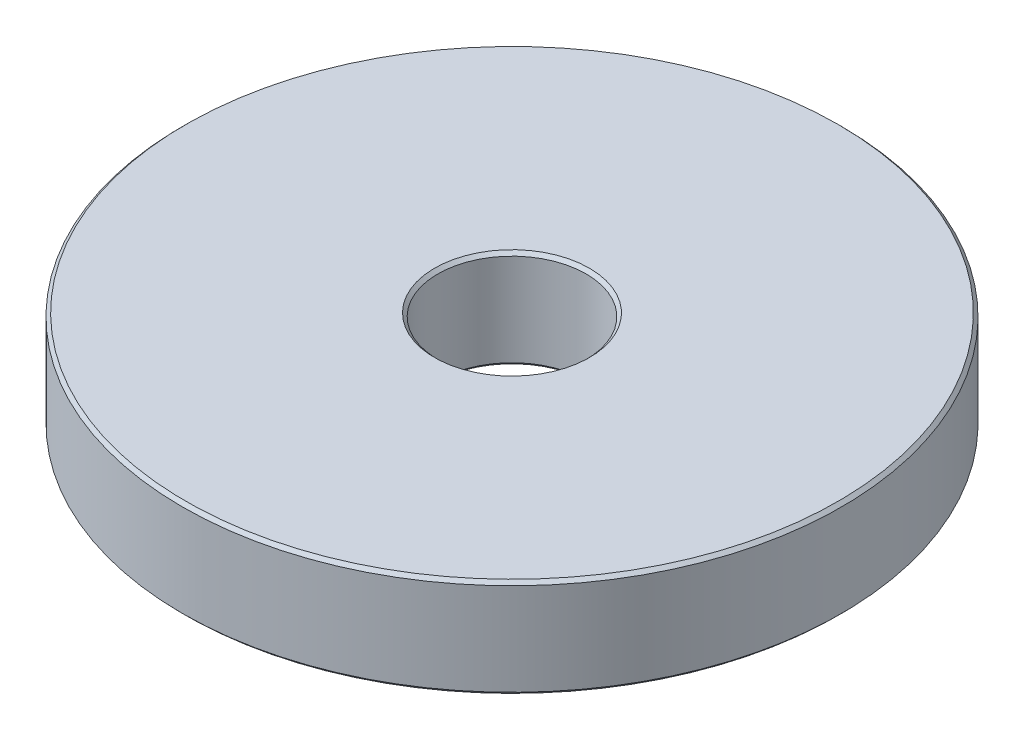
from build123d import *


with BuildPart() as part:
    # Sketch1 → Revolve1 (revolve)
    with BuildSketch(Plane.XY):
        Polygon((4.7, -9.5), (19.8, -9.5), (20, -9.3), (20, -3.7), (19.8, -3.5), (4.7, -3.5), (4.5, -3.7), (4.5, -9.3), align=None)
    revolve(axis=Axis((0, 9.5, 0), (0, -1, 0)))


solid = part.part
